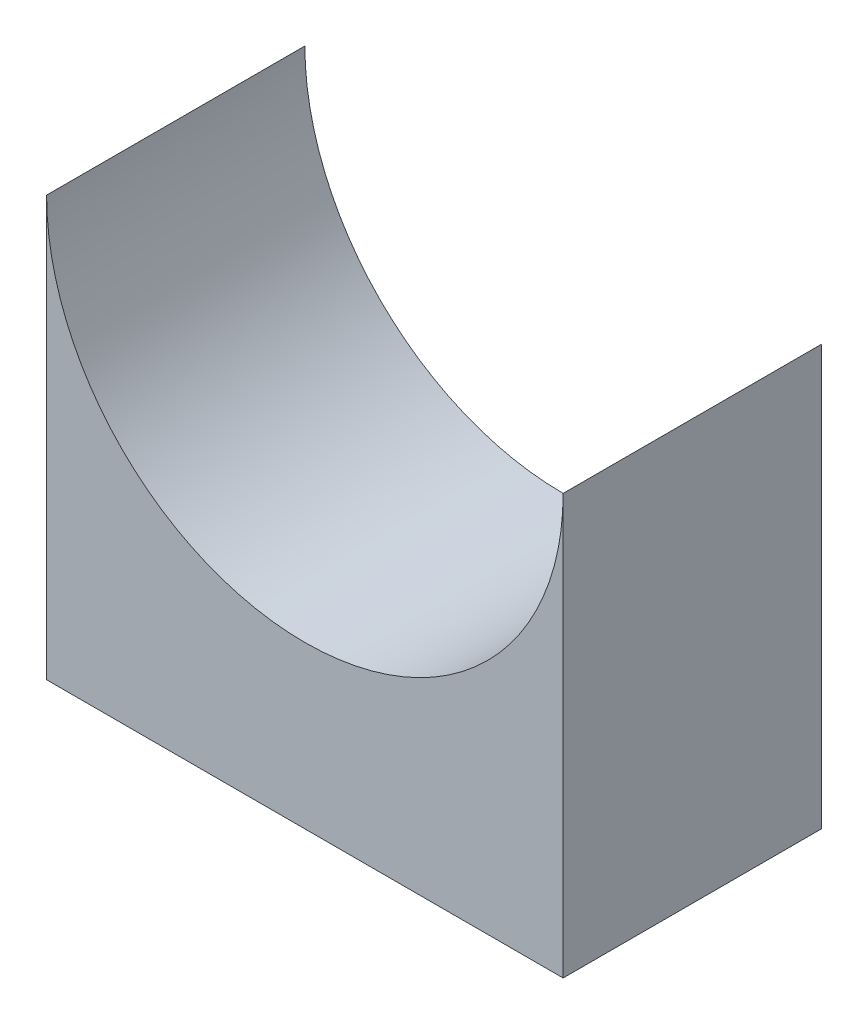
from build123d import *

# Parameters (mm, degrees)
BOSS_EXTRUDE1_DEPTH = 20


with BuildPart() as part:
    # Sketch1 → Boss-Extrude1 (new body)
    with BuildSketch(Plane.XY):
        with BuildLine():
            Line((0, 0), (40, 0))
            Line((40, 0), (40, 32.5))
            ThreePointArc((40, 32.5), (20, 12.5), (0, 32.5))
            Line((0, 32.5), (0, 0))
        make_face()
    extrude(amount=BOSS_EXTRUDE1_DEPTH)


solid = part.part
